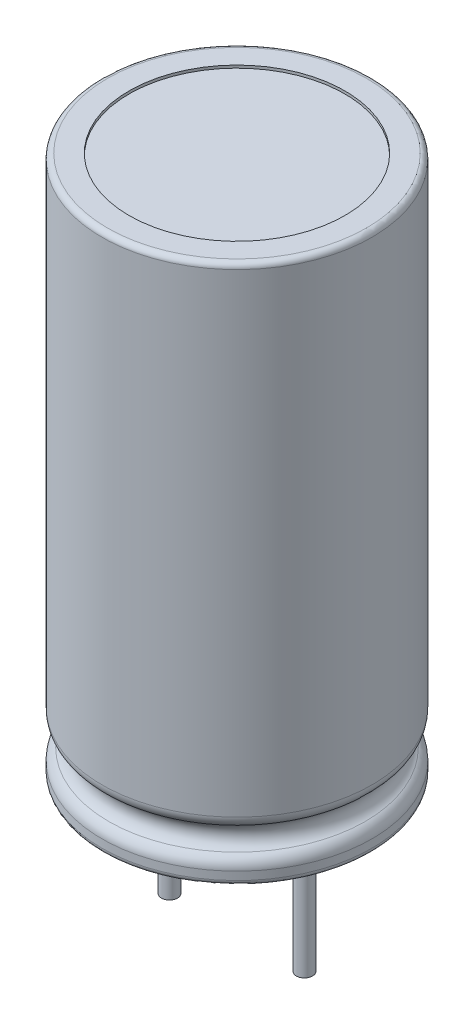
from build123d import *

# Parameters (mm, degrees)
FILLET2_R             = 0.2
SKETCH3_R             = 4
CUT_EXTRUDE1_DEPTH    = 0.1
SKETCH4_R             = 4
CUT_EXTRUDE2_DEPTH    = 0.1
SKETCH2_R             = 0.3
BOSS_EXTRUDE1_DEPTH   = 5
BOSS_EXTRUDE1_2_DEPTH = 5


with BuildPart() as part:
    # Sketch1 → Revolve1 (revolve)
    with BuildSketch(Plane.XY):
        with BuildLine():
            Line((0, 0), (0, 20))
            Line((0, 20), (-5, 20))
            Line((-5, 20), (-5, 2.232050808))
            ThreePointArc((-5, 2.232050808), (-4.933012702, 1.982050808), (-4.75, 1.799038106))
            ThreePointArc((-4.75, 1.799038106), (-4.5, 1.366025404), (-4.75, 0.933012702))
            ThreePointArc((-4.75, 0.933012702), (-4.933012702, 0.75), (-5, 0.5))
            Line((-5, 0.5), (-5, 0))
            Line((-5, 0), (0, 0))
        make_face()
    revolve(axis=Axis((0, 0, 0), (0, 1, 0)))

    # Fillet2
    fillet2_edges = [part.edges().sort_by_distance(p)[0] for p in [
        (5, 0, 0),
        (5, 20, 0),
    ]]
    fillet(fillet2_edges, radius=FILLET2_R)

    # Sketch3 → Cut-Extrude1 (cut)
    with BuildSketch(Plane(origin=(0, 20, 0), x_dir=(1, 0, 0), z_dir=(0, 1, 0))):
        Circle(SKETCH3_R)
    extrude(amount=-CUT_EXTRUDE1_DEPTH, mode=Mode.SUBTRACT)

    # Sketch4 → Cut-Extrude2 (cut)
    with BuildSketch(Plane.XZ):
        Circle(SKETCH4_R)
    extrude(amount=-CUT_EXTRUDE2_DEPTH, mode=Mode.SUBTRACT)


with BuildPart() as body_2:
    # Sketch2 → Boss-Extrude1 (new body, symmetric)
    with BuildSketch(Plane.XZ):
        with Locations((-2.5, 0)):
            Circle(SKETCH2_R)
    extrude(amount=BOSS_EXTRUDE1_DEPTH, both=True)


with BuildPart() as body_3:
    # Sketch2 → Boss-Extrude1 2 (new body, symmetric)
    with BuildSketch(Plane.XZ):
        with Locations((2.5, 0)):
            Circle(SKETCH2_R)
    extrude(amount=BOSS_EXTRUDE1_2_DEPTH, both=True)


solid = Compound([part.part, body_2.part, body_3.part])
